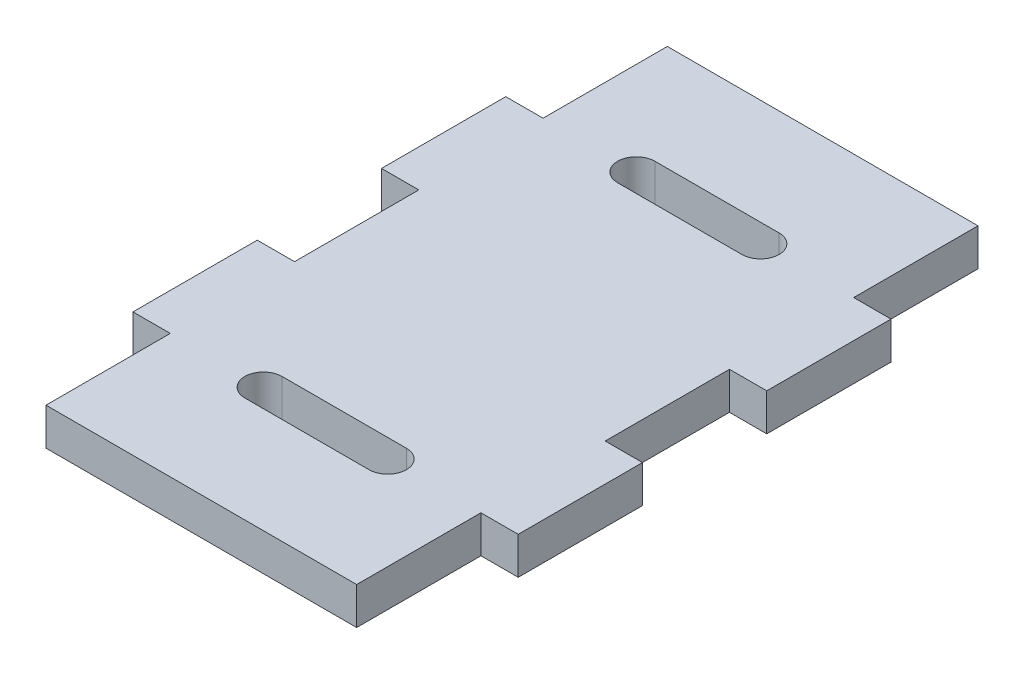
from build123d import *

# Parameters (mm, degrees)
SKETCH1_W           = 25
SKETCH1_H           = 50
BOSS_EXTRUDE1_DEPTH = 3
SKETCH2_W           = 3
SKETCH2_H           = 10
BOSS_EXTRUDE2_DEPTH = 3


with BuildPart() as part:
    # Sketch1 → Boss-Extrude1 (new body)
    with BuildSketch(Plane(origin=(0, 0, 0), x_dir=(1, 0, 0), z_dir=(0, 1, 0))):
        Rectangle(SKETCH1_W, SKETCH1_H)
        with BuildLine():
            Line((-5, 16.5), (5, 16.5))
            ThreePointArc((5, 16.5), (6.5, 15), (5, 13.5))
            Line((5, 13.5), (-5, 13.5))
            ThreePointArc((-5, 13.5), (-6.5, 15), (-5, 16.5))
        make_face(mode=Mode.SUBTRACT)
        with BuildLine():
            Line((-5, -16.5), (5, -16.5))
            ThreePointArc((5, -16.5), (6.5, -15), (5, -13.5))
            Line((5, -13.5), (-5, -13.5))
            ThreePointArc((-5, -13.5), (-6.5, -15), (-5, -16.5))
        make_face(mode=Mode.SUBTRACT)
    extrude(amount=BOSS_EXTRUDE1_DEPTH)

    # Sketch2 → Boss-Extrude2 (add)
    with BuildSketch(Plane(origin=(0, 3, 0), x_dir=(1, 0, 0), z_dir=(0, 1, 0))):
        with Locations((14, 10)):
            Rectangle(SKETCH2_W, SKETCH2_H)
        with Locations((14, -10)):
            Rectangle(SKETCH2_W, SKETCH2_H)
        with Locations((-14, -10)):
            Rectangle(SKETCH2_W, SKETCH2_H)
        with Locations((-14, 10)):
            Rectangle(SKETCH2_W, SKETCH2_H)
    extrude(amount=-BOSS_EXTRUDE2_DEPTH)


solid = part.part
